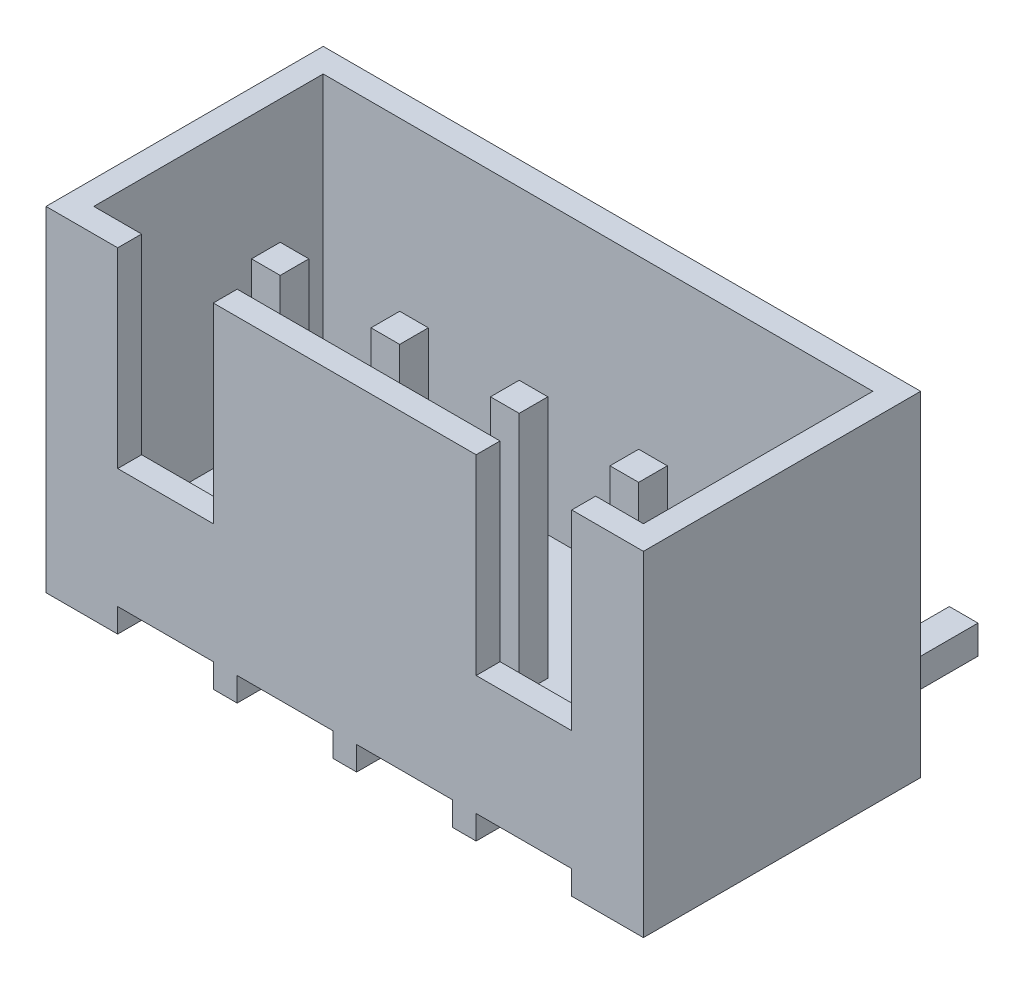
from build123d import *

# Parameters (mm, degrees)
EXTRUDE_1_DEPTH     = 5.8
SKETCH_2_W          = 11.5
SKETCH_2_H          = 4.8
CUT_EXTRUDE_1_DEPTH = 6
SKETCH_3_W          = 0.6
SKETCH_3_H          = 0.6
EXTRUDE_2_DEPTH     = 6.1
SKETCH_4_W          = 0.6
SKETCH_4_H          = 0.6
EXTRUDE_3_DEPTH     = 7.1
SKETCH_5_W          = 2
SKETCH_5_H          = 4
CUT_EXTRUDE_2_DEPTH = 1


with BuildPart() as part:
    # 草图1 → 凸台-拉伸1 (new body)
    with BuildSketch(Plane.XY):
        Polygon((4, 0), (4, 0.5), (6, 0.5), (6, 0), (6.5, 0), (6.5, 0.5), (8.5, 0.5), (8.5, 0), (9, 0), (9, 0.5), (11, 0.5), (11, 0), (12.5, 0), (12.5, 7), (0, 7), (0, 0), (1.5, 0), (1.5, 0.5), (3.5, 0.5), (3.5, 0), align=None)
    extrude(amount=EXTRUDE_1_DEPTH)

    # 草图2 → 切除-拉伸1 (cut)
    with BuildSketch(Plane(origin=(0, 7, 0), x_dir=(1, 0, 0), z_dir=(0, 1, 0))):
        with Locations((6.25, -2.9)):
            Rectangle(SKETCH_2_W, SKETCH_2_H)
    extrude(amount=-CUT_EXTRUDE_1_DEPTH, mode=Mode.SUBTRACT)

    # 草图3 → 凸台-拉伸2 (add)
    with BuildSketch(Plane.XZ):
        with Locations((5, 3.4)):
            Rectangle(SKETCH_3_W, SKETCH_3_H)
        with Locations((7.5, 3.4)):
            Rectangle(SKETCH_3_W, SKETCH_3_H)
        with Locations((2.5, 3.4)):
            Rectangle(SKETCH_3_W, SKETCH_3_H)
        with Locations((10, 3.4)):
            Rectangle(SKETCH_3_W, SKETCH_3_H)
    extrude(amount=-EXTRUDE_2_DEPTH)

    # 草图4 → 凸台-拉伸3 (add)
    with BuildSketch(Plane.XY.offset(3.7)):
        with Locations((5, -0.3)):
            Rectangle(SKETCH_4_W, SKETCH_4_H)
        with Locations((7.5, -0.3)):
            Rectangle(SKETCH_4_W, SKETCH_4_H)
        with Locations((2.5, -0.3)):
            Rectangle(SKETCH_4_W, SKETCH_4_H)
        with Locations((10, -0.3)):
            Rectangle(SKETCH_4_W, SKETCH_4_H)
    extrude(amount=-EXTRUDE_3_DEPTH)

    # 草图5 → 切除-拉伸2 (cut)
    with BuildSketch(Plane.XY.offset(5.8)):
        with Locations((2.5, 5)):
            Rectangle(SKETCH_5_W, SKETCH_5_H)
        with Locations((10, 5)):
            Rectangle(SKETCH_5_W, SKETCH_5_H)
    extrude(amount=-CUT_EXTRUDE_2_DEPTH, mode=Mode.SUBTRACT)


solid = part.part
